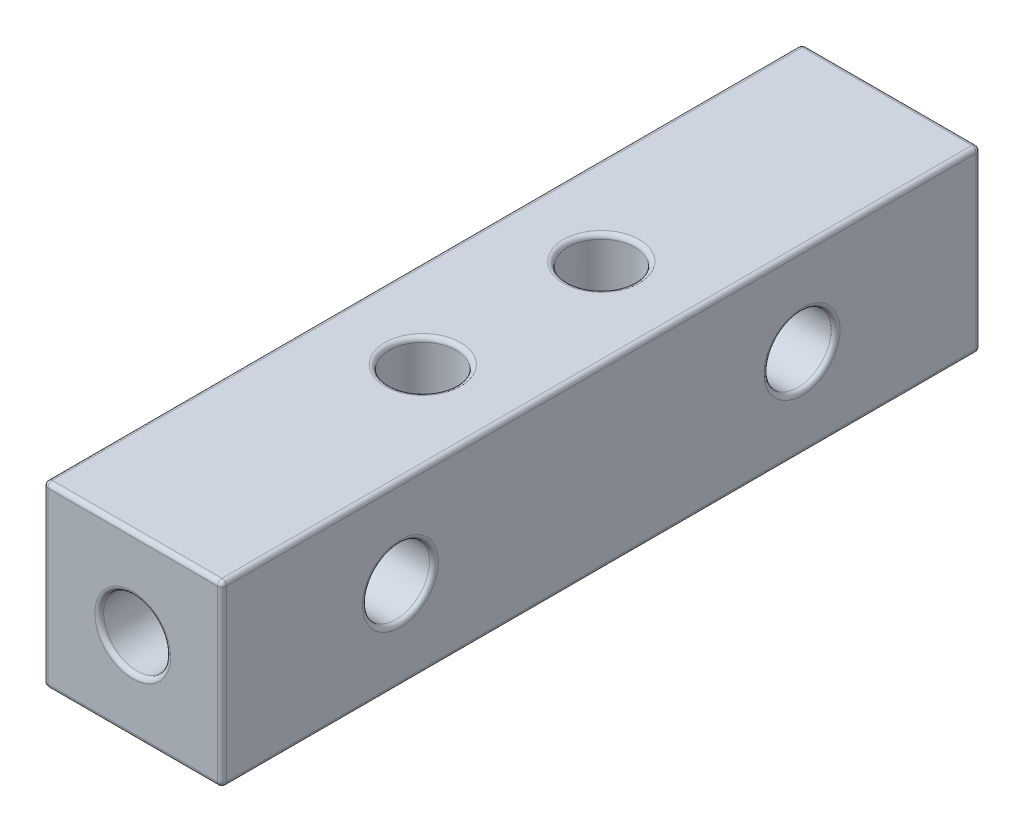
from build123d import *

# Parameters (mm, degrees)
SKETCH_1_W          = 8
SKETCH_1_H          = 8
EXTRUDE_1_DEPTH     = 34
SKETCH_2_R          = 1.5
CUT_EXTRUDE_1_DEPTH = 10
SKETCH_3_R          = 1.5
CUT_EXTRUDE_2_DEPTH = 9
SKETCH_4_R          = 1.5
CUT_EXTRUDE_3_DEPTH = 9
FILLET_1_R          = 0.2
FILLET_2_R          = 0.2


with BuildPart() as part:
    # 草图1 → 凸台-拉伸1 (new body)
    with BuildSketch(Plane.XY):
        Rectangle(SKETCH_1_W, SKETCH_1_H)
    extrude(amount=EXTRUDE_1_DEPTH)

    # 草图2 → 切除-拉伸1 (cut)
    with BuildSketch(Plane.XY.offset(34)):
        Circle(SKETCH_2_R)
    extrude(amount=-CUT_EXTRUDE_1_DEPTH, mode=Mode.SUBTRACT)

    # 草图3 → 切除-拉伸2 (cut, through all)
    with BuildSketch(Plane(origin=(0, 4, 0), x_dir=(1, 0, 0), z_dir=(0, 1, 0))):
        with Locations((0, -21)):
            Circle(SKETCH_3_R)
        with Locations((0, -13)):
            Circle(SKETCH_3_R)
    extrude(amount=-CUT_EXTRUDE_2_DEPTH, mode=Mode.SUBTRACT)

    # 草图4 → 切除-拉伸3 (cut, through all)
    with BuildSketch(Plane(origin=(4, 0, 0), x_dir=(0, 0, -1), z_dir=(1, 0, 0))):
        with Locations((-8, 0)):
            Circle(SKETCH_4_R)
        with Locations((-26, 0)):
            Circle(SKETCH_4_R)
    extrude(amount=-CUT_EXTRUDE_3_DEPTH, mode=Mode.SUBTRACT)

    # 圆角1
    fillet_1_edges = [part.edges().sort_by_distance(p)[0] for p in [
        (-4, 0, 34),
        (0, -4, 34),
        (-1.5, -4, 21),
        (-1.5, -4, 13),
        (-4, 0, 9.5),
        (-4, 0, 27.5),
        (4, 0, 34),
        (0, -4, 0),
        (-4, 0, 0),
        (0, 4, 0),
        (4, 0, 0),
        (4, -4, 17),
        (-4, -4, 17),
        (-4, 4, 17),
        (4, 4, 17),
        (0, 4, 34),
    ]]
    fillet(fillet_1_edges, radius=FILLET_1_R)

    # 圆角2
    fillet_2_edges = [part.edges().sort_by_distance(p)[0] for p in [
        (-1.5, 0, 34),
        (-1.5, 4, 21),
        (-1.5, 4, 13),
        (4, 0, 9.5),
        (4, 0, 27.5),
    ]]
    fillet(fillet_2_edges, radius=FILLET_2_R)


solid = part.part
